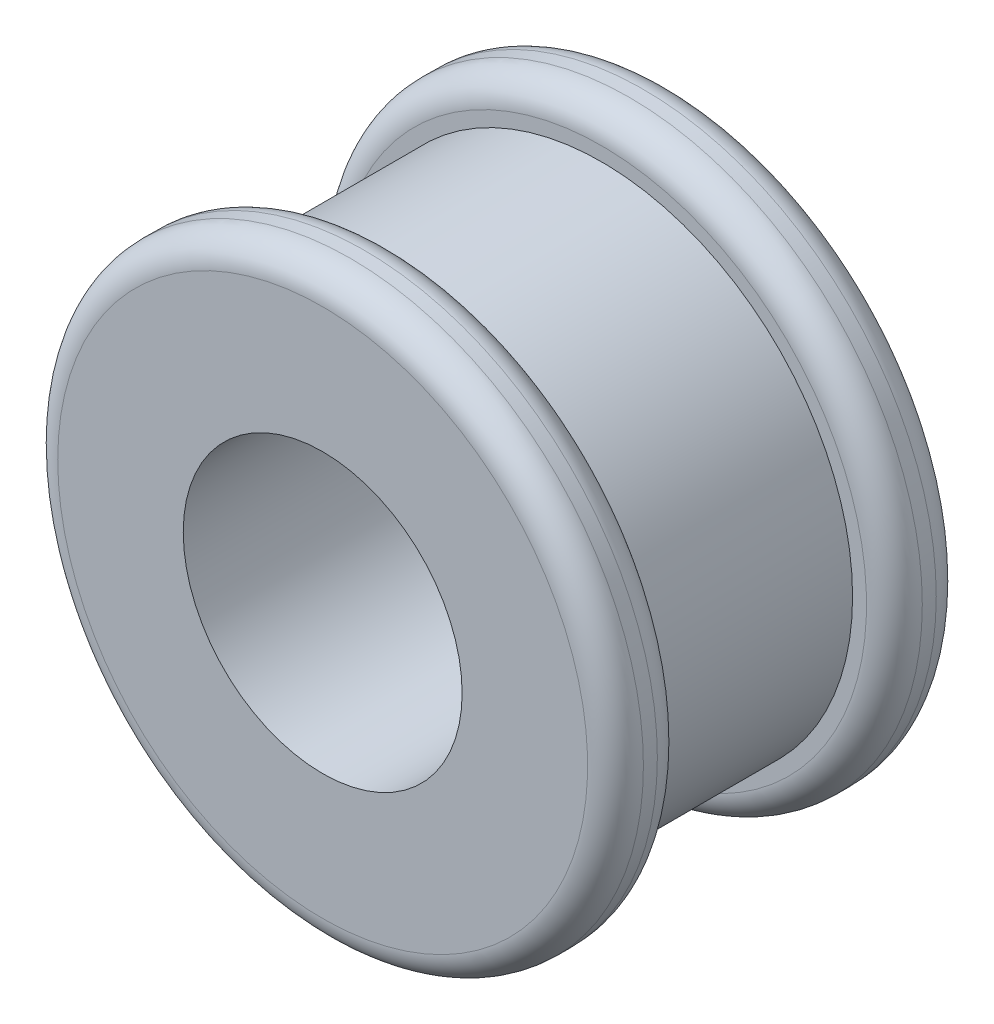
from build123d import *

# Parameters (mm, degrees)
FILLET1_R = 2


with BuildPart() as part:
    # Sketch1 → Revolve1 (revolve)
    with BuildSketch(Plane(origin=(0, 0, 0), x_dir=(0, 0, -1), z_dir=(1, 0, 0))):
        Polygon((0, 10), (25, 10), (25, 21), (20, 21), (20, 18), (5, 18), (5, 21), (0, 21), align=None)
    revolve(axis=Axis((0, 0, 0), (0, 0, -1)))

    # Fillet1
    fillet1_edges = [part.edges().sort_by_distance(p)[0] for p in [
        (0, -21, 0),
        (0, -21, -5),
        (0, -21, -20),
        (0, -21, -25),
    ]]
    fillet(fillet1_edges, radius=FILLET1_R)


solid = part.part
